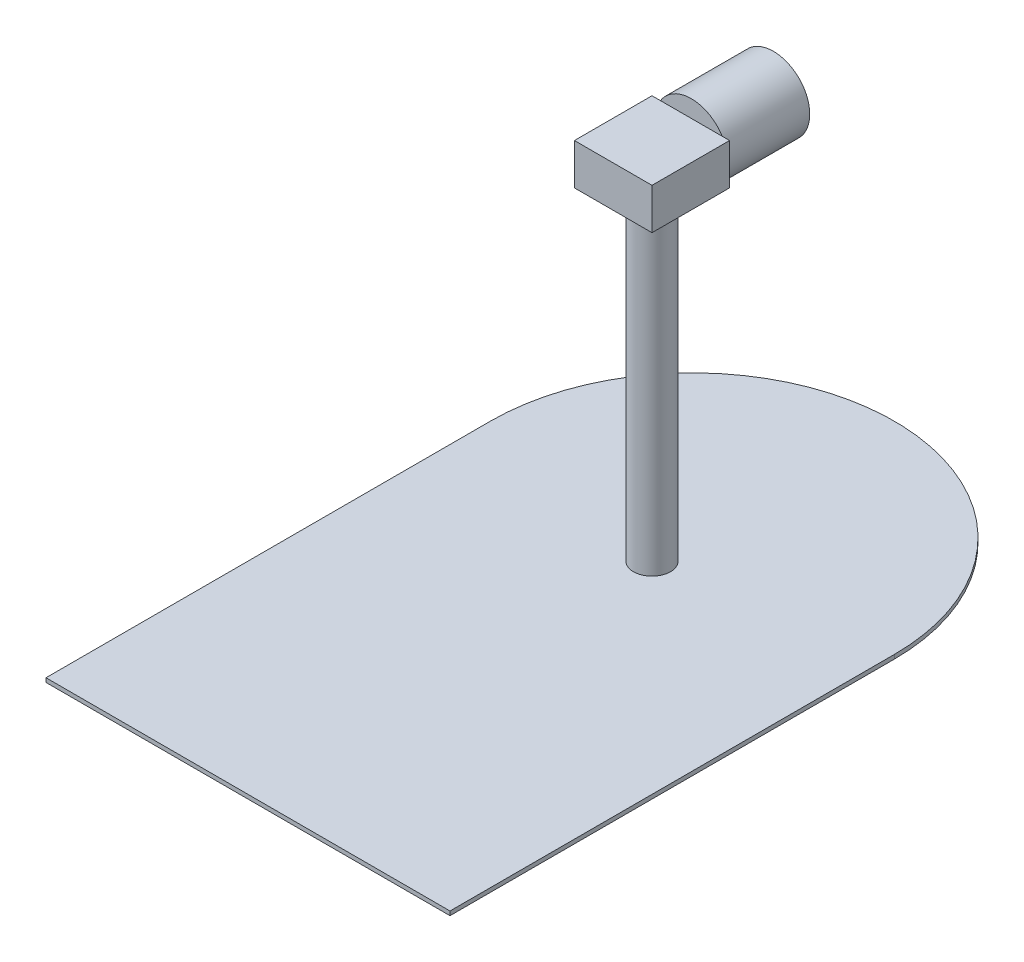
from build123d import *

# Parameters (mm, degrees)
BOSS_EXTRUDE1_DEPTH = 2.54
SKETCH2_R           = 11.439475367
BOSS_EXTRUDE2_DEPTH = 200
SKETCH3_W           = 48.000000012
SKETCH3_H           = 48.000000012
BOSS_EXTRUDE3_DEPTH = 25.4
SKETCH4_R           = 22.499999958
BOSS_EXTRUDE4_DEPTH = 50.8


with BuildPart() as part:
    # Sketch1 → Boss-Extrude1 (new body)
    with BuildSketch(Plane(origin=(0, 0, 0), x_dir=(1, 0, 0), z_dir=(0, 1, 0))):
        with BuildLine():
            Line((132.671256636, -150.479823869), (-117.328743364, -150.479823869))
            Line((-117.328743364, -150.479823869), (-117.328743364, 124.520176131))
            ThreePointArc((-117.328743364, 124.520176131), (7.671256636, 249.520176131), (132.671256636, 124.520176131))
            Line((132.671256636, 124.520176131), (132.671256636, -150.479823869))
        make_face()
    extrude(amount=BOSS_EXTRUDE1_DEPTH)

    # Sketch2 → Boss-Extrude2 (add)
    with BuildSketch(Plane(origin=(0, 2.54, 0), x_dir=(1, 0, 0), z_dir=(0, 1, 0))):
        with Locations((7.671256636, 99.520176157)):
            Circle(SKETCH2_R)
    extrude(amount=BOSS_EXTRUDE2_DEPTH)

    # Sketch3 → Boss-Extrude3 (add)
    with BuildSketch(Plane(origin=(0, 202.54, 0), x_dir=(1, 0, 0), z_dir=(0, 1, 0))):
        with Locations((7.671256636, 99.520176157)):
            Rectangle(SKETCH3_W, SKETCH3_H)
    extrude(amount=BOSS_EXTRUDE3_DEPTH)

    # Sketch4 → Boss-Extrude4 (add)
    with BuildSketch(Plane(origin=(0, 0, -123.520176163), x_dir=(-1, 0, 0), z_dir=(0, 0, -1))):
        with Locations((-8.000795549, 216.051385612)):
            Circle(SKETCH4_R)
    extrude(amount=BOSS_EXTRUDE4_DEPTH)


solid = part.part
